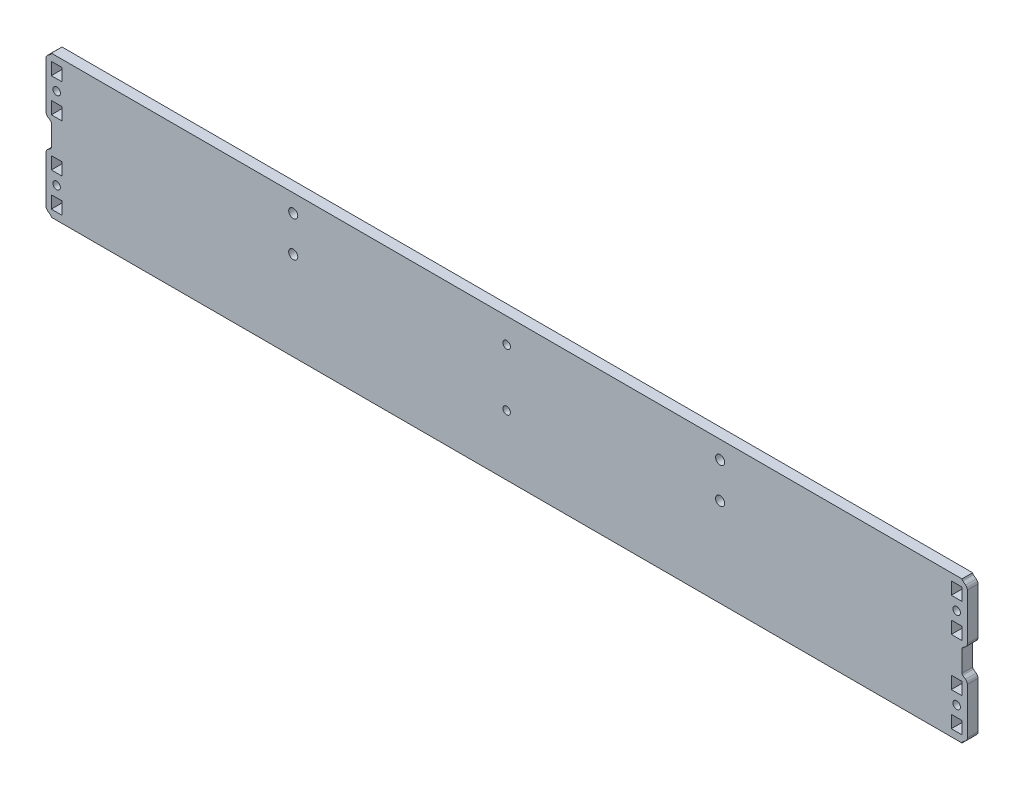
from build123d import *

# Parameters (mm, degrees)
SKETCH_1_W           = 512
SKETCH_1_H           = 79.917657137
EXTRUDE_1_DEPTH      = 6
SKETCH_2_R           = 2.1
SKETCH_2_R_2         = 2.55
CUT_EXTRUDE_1_DEPTH  = 7
EXTRUDE_2_DEPTH      = 6
SKETCH_3_R           = 2.1
SKETCH_3_W           = 7
SKETCH_3_H           = 6
CUT_EXTRUDE_11_DEPTH = 7
EXTRUDE_21_DEPTH     = 6
SKETCH_31_R          = 2.1
SKETCH_31_W          = 7
SKETCH_31_H          = 6
CUT_EXTRUDE_12_DEPTH = 7
EXTRUDE_22_DEPTH     = 6
SKETCH_32_R          = 2.1
SKETCH_32_W          = 7
SKETCH_32_H          = 6
CUT_EXTRUDE_13_DEPTH = 7
EXTRUDE_23_DEPTH     = 6
SKETCH_33_R          = 2.1
SKETCH_33_W          = 7
SKETCH_33_H          = 6
CUT_EXTRUDE_14_DEPTH = 7


with BuildPart() as part:
    # Эскиз1 → Бобышка-Вытянуть1 (new body)
    with BuildSketch(Plane.XY):
        with Locations((256, -204.420367031)):
            Rectangle(SKETCH_1_W, SKETCH_1_H)
    extrude(amount=EXTRUDE_1_DEPTH)

    # Эскиз2 → Вырез-Вытянуть1 (cut, through all)
    with BuildSketch(Plane.XY.offset(6)):
        with Locations((256, -178.461538462)):
            Circle(SKETCH_2_R)
        with Locations((256, -210.461538462)):
            Circle(SKETCH_2_R)
        with Locations((136, -174.461538462)):
            Circle(SKETCH_2_R_2)
        with Locations((136, -194.461538462)):
            Circle(SKETCH_2_R_2)
        with Locations((376, -174.461538462)):
            Circle(SKETCH_2_R_2)
        with Locations((376, -194.461538462)):
            Circle(SKETCH_2_R_2)
    extrude(amount=-CUT_EXTRUDE_1_DEPTH, mode=Mode.SUBTRACT)

    # Эскиз21 → Бобышка-Вытянуть2 (add)
    with BuildSketch(Plane(origin=(50, -181.461538462, 0), x_dir=(0, 1, 0), z_dir=(0, 0, 1))):
        with BuildLine():
            Line((13, 53), (-13, 53))
            ThreePointArc((-13, 53), (-14.118033989, 52.736067977), (-15, 52))
            Line((-15, 52), (-16.2, 50.4))
            ThreePointArc((-16.2, 50.4), (-16.552786405, 50.105572809), (-17, 50))
            Line((-17, 50), (17, 50))
            ThreePointArc((17, 50), (16.552786405, 50.105572809), (16.2, 50.4))
            Line((16.2, 50.4), (15, 52))
            ThreePointArc((15, 52), (14.118033989, 52.736067977), (13, 53))
        make_face()
    extrude(amount=EXTRUDE_2_DEPTH)

    # Эскиз3 → Вырез-Вытянуть11 (cut, through all)
    with BuildSketch(Plane(origin=(50, -181.461538462, 6), x_dir=(0, 1, 0), z_dir=(0, 0, 1))):
        with Locations((0, 47)):
            Circle(SKETCH_3_R)
        with Locations((9.531849908, 47)):
            Rectangle(SKETCH_3_W, SKETCH_3_H)
        with Locations((-9.531849908, 47)):
            Rectangle(SKETCH_3_W, SKETCH_3_H)
    extrude(amount=-CUT_EXTRUDE_11_DEPTH, mode=Mode.SUBTRACT)

    # Эскиз22 → Бобышка-Вытянуть21 (add)
    with BuildSketch(Plane(origin=(50, -227.379195599, 0), x_dir=(0, 1, 0), z_dir=(0, 0, 1))):
        with BuildLine():
            Line((13, 53), (-13, 53))
            ThreePointArc((-13, 53), (-14.118033989, 52.736067977), (-15, 52))
            Line((-15, 52), (-16.2, 50.4))
            ThreePointArc((-16.2, 50.4), (-16.552786405, 50.105572809), (-17, 50))
            Line((-17, 50), (17, 50))
            ThreePointArc((17, 50), (16.552786405, 50.105572809), (16.2, 50.4))
            Line((16.2, 50.4), (15, 52))
            ThreePointArc((15, 52), (14.118033989, 52.736067977), (13, 53))
        make_face()
    extrude(amount=EXTRUDE_21_DEPTH)

    # Эскиз31 → Вырез-Вытянуть12 (cut, through all)
    with BuildSketch(Plane(origin=(50, -227.379195599, 6), x_dir=(0, 1, 0), z_dir=(0, 0, 1))):
        with Locations((0, 47)):
            Circle(SKETCH_31_R)
        with Locations((9.531849908, 47)):
            Rectangle(SKETCH_31_W, SKETCH_31_H)
        with Locations((-9.531849908, 47)):
            Rectangle(SKETCH_31_W, SKETCH_31_H)
    extrude(amount=-CUT_EXTRUDE_12_DEPTH, mode=Mode.SUBTRACT)

    # Эскиз23 → Бобышка-Вытянуть22 (add)
    with BuildSketch(Plane(origin=(462, -181.461538462, 0), x_dir=(0, -1, 0), z_dir=(0, 0, 1))):
        with BuildLine():
            Line((13, 53), (-13, 53))
            ThreePointArc((-13, 53), (-14.118033989, 52.736067977), (-15, 52))
            Line((-15, 52), (-16.2, 50.4))
            ThreePointArc((-16.2, 50.4), (-16.552786405, 50.105572809), (-17, 50))
            Line((-17, 50), (17, 50))
            ThreePointArc((17, 50), (16.552786405, 50.105572809), (16.2, 50.4))
            Line((16.2, 50.4), (15, 52))
            ThreePointArc((15, 52), (14.118033989, 52.736067977), (13, 53))
        make_face()
    extrude(amount=EXTRUDE_22_DEPTH)

    # Эскиз32 → Вырез-Вытянуть13 (cut, through all)
    with BuildSketch(Plane(origin=(462, -181.461538462, 6), x_dir=(0, -1, 0), z_dir=(0, 0, 1))):
        with Locations((0, 47)):
            Circle(SKETCH_32_R)
        with Locations((9.531849908, 47)):
            Rectangle(SKETCH_32_W, SKETCH_32_H)
        with Locations((-9.531849908, 47)):
            Rectangle(SKETCH_32_W, SKETCH_32_H)
    extrude(amount=-CUT_EXTRUDE_13_DEPTH, mode=Mode.SUBTRACT)

    # Эскиз24 → Бобышка-Вытянуть23 (add)
    with BuildSketch(Plane(origin=(462, -227.379195599, 0), x_dir=(0, -1, 0), z_dir=(0, 0, 1))):
        with BuildLine():
            Line((13, 53), (-13, 53))
            ThreePointArc((-13, 53), (-14.118033989, 52.736067977), (-15, 52))
            Line((-15, 52), (-16.2, 50.4))
            ThreePointArc((-16.2, 50.4), (-16.552786405, 50.105572809), (-17, 50))
            Line((-17, 50), (17, 50))
            ThreePointArc((17, 50), (16.552786405, 50.105572809), (16.2, 50.4))
            Line((16.2, 50.4), (15, 52))
            ThreePointArc((15, 52), (14.118033989, 52.736067977), (13, 53))
        make_face()
    extrude(amount=EXTRUDE_23_DEPTH)

    # Эскиз33 → Вырез-Вытянуть14 (cut, through all)
    with BuildSketch(Plane(origin=(462, -227.379195599, 6), x_dir=(0, -1, 0), z_dir=(0, 0, 1))):
        with Locations((0, 47)):
            Circle(SKETCH_33_R)
        with Locations((9.531849908, 47)):
            Rectangle(SKETCH_33_W, SKETCH_33_H)
        with Locations((-9.531849908, 47)):
            Rectangle(SKETCH_33_W, SKETCH_33_H)
    extrude(amount=-CUT_EXTRUDE_14_DEPTH, mode=Mode.SUBTRACT)


solid = part.part
